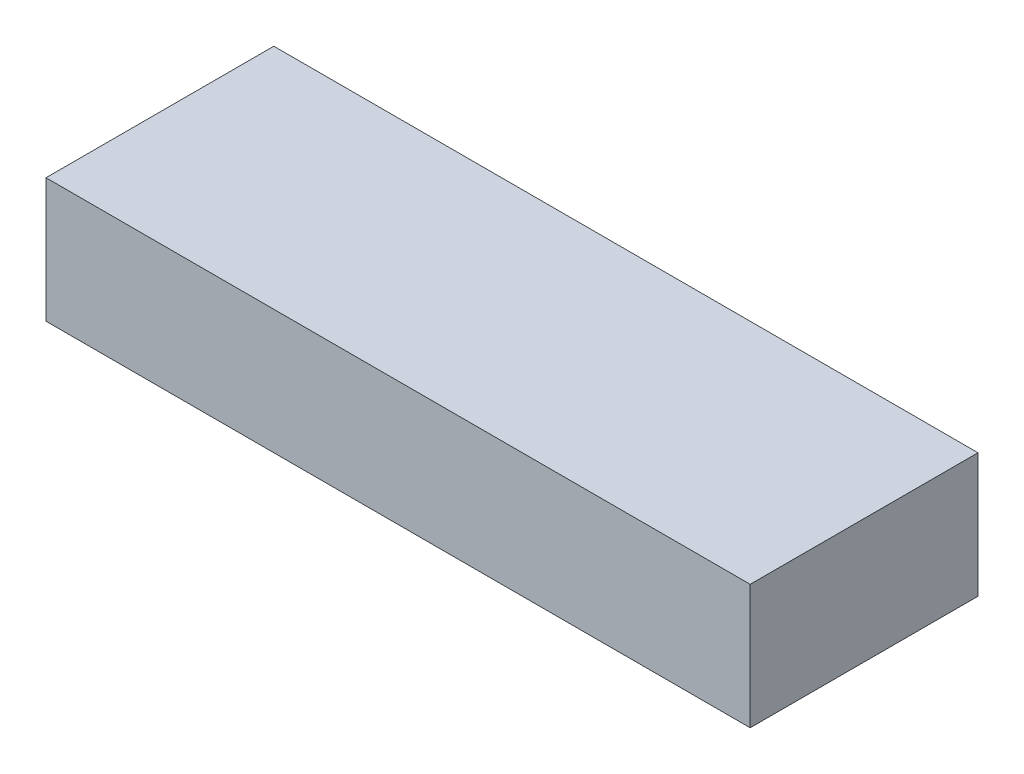
from build123d import *

# Parameters (mm, degrees)
SKETCH1_W           = 136
SKETCH1_H           = 44
BOSS_EXTRUDE1_DEPTH = 24


with BuildPart() as part:
    # Sketch1 → Boss-Extrude1 (new body)
    with BuildSketch(Plane(origin=(0, 0, 0), x_dir=(1, 0, 0), z_dir=(0, 1, 0))):
        with Locations((7.295612669, 12.566666667)):
            Rectangle(SKETCH1_W, SKETCH1_H)
    extrude(amount=BOSS_EXTRUDE1_DEPTH)


solid = part.part
